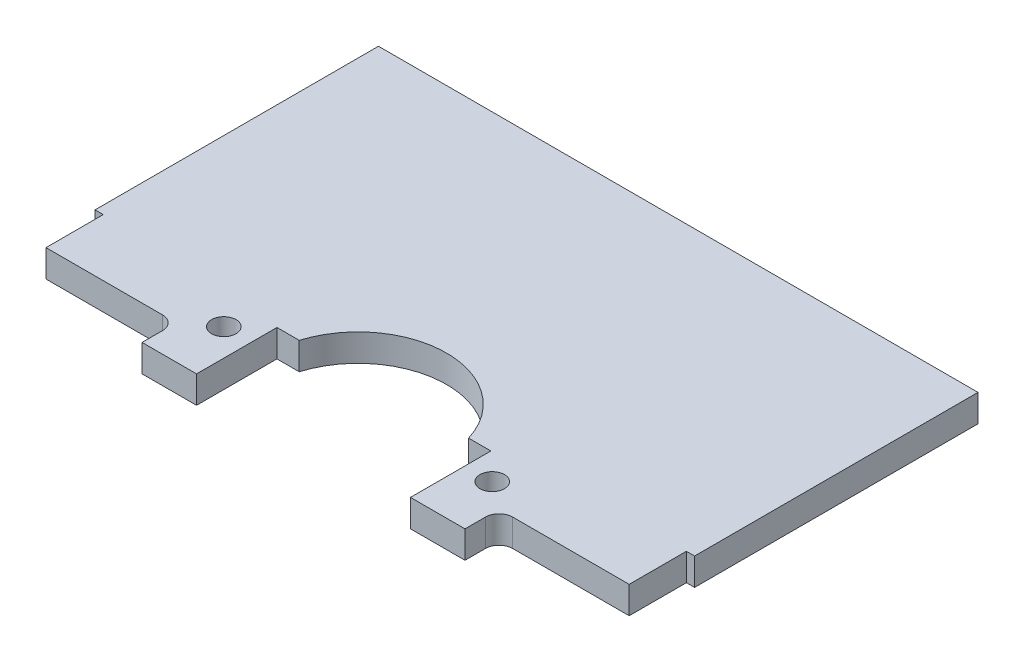
from build123d import *

# Parameters (mm, degrees)
SKETCH1_R  = 1.143
SKETCH1_W  = 5.08
SKETCH1_H  = 3.175
BODY_DEPTH = 2.54
FILLET1_R  = 1.27


with BuildPart() as part:
    # Sketch1 → body (new body)
    with BuildSketch(Plane(origin=(0, 0, 0), x_dir=(1, 0, 0), z_dir=(0, 1, 0))):
        with BuildLine():
            Line((-27.94, 13.208), (-27.94, -13.208))
            Line((-27.94, -13.208), (-27.178, -13.208))
            Line((-27.178, -13.208), (-7.509126714, -13.208))
            ThreePointArc((-7.509126714, -13.208), (0, -8.382), (7.509126714, -13.208))
            Line((7.509126714, -13.208), (27.178, -13.208))
            Line((27.178, -13.208), (27.94, -13.208))
            Line((27.94, -13.208), (27.94, 13.208))
            Line((27.94, 13.208), (-27.94, 13.208))
        make_face()
        with BuildLine():
            Line((-7.509126714, -13.208), (-27.178, -13.208))
            Line((-27.178, -13.208), (-27.178, -18.542))
            Line((-27.178, -18.542), (-15.0495, -18.542))
            Line((-15.0495, -18.542), (-9.9695, -18.542))
            Line((-9.9695, -18.542), (-9.9695, -14.224))
            Line((-9.9695, -14.224), (-7.894457296, -14.224))
            ThreePointArc((-7.894457296, -14.224), (-7.718527326, -13.709652922), (-7.509126714, -13.208))
        make_face()
        with Locations((-12.5095, -16.637)):
            Circle(SKETCH1_R, mode=Mode.SUBTRACT)
        with BuildLine():
            Line((27.178, -13.208), (7.509126714, -13.208))
            ThreePointArc((7.509126714, -13.208), (7.718527326, -13.709652922), (7.894457296, -14.224))
            Line((7.894457296, -14.224), (9.9695, -14.224))
            Line((9.9695, -14.224), (9.9695, -18.542))
            Line((9.9695, -18.542), (15.0495, -18.542))
            Line((15.0495, -18.542), (27.178, -18.542))
            Line((27.178, -18.542), (27.178, -13.208))
        make_face()
        with Locations((12.5095, -16.637)):
            Circle(SKETCH1_R, mode=Mode.SUBTRACT)
        with Locations((-12.5095, -20.1295)):
            Rectangle(SKETCH1_W, SKETCH1_H)
        with Locations((12.5095, -20.1295)):
            Rectangle(SKETCH1_W, SKETCH1_H)
    extrude(amount=BODY_DEPTH)

    # Fillet1
    fillet1_edges = [part.edges().sort_by_distance(p)[0] for p in [
        (15.0495, 1.27, 18.542),
        (-15.0495, 1.27, 18.542),
    ]]
    fillet(fillet1_edges, radius=FILLET1_R)


solid = part.part
